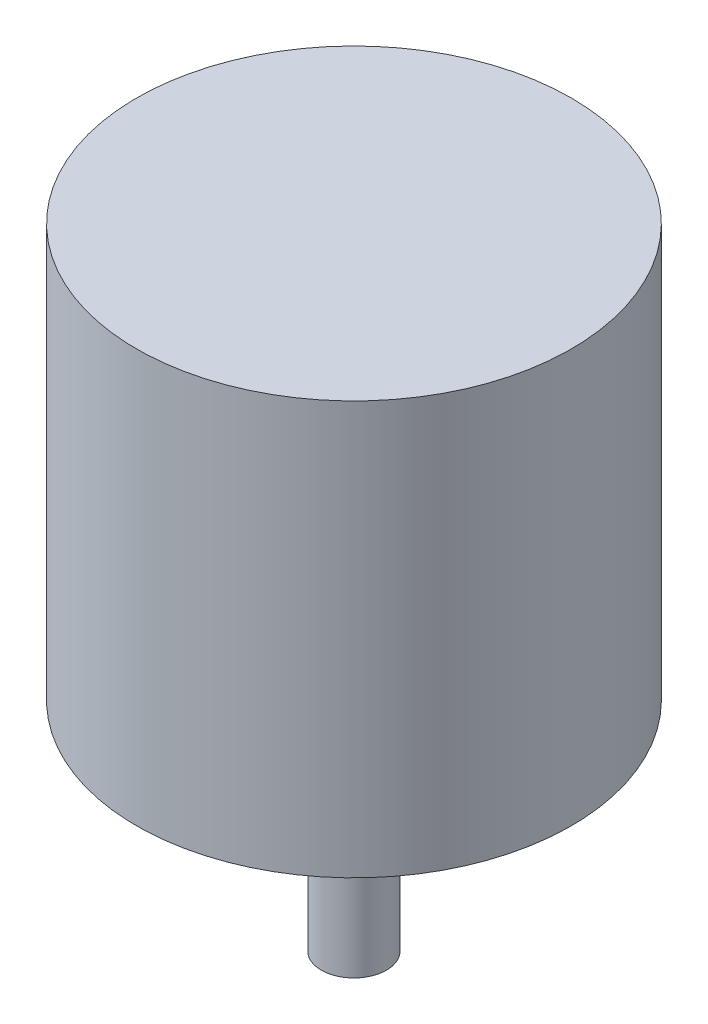
from build123d import *

# Parameters (mm, degrees)
ESBO_O11_R               = 20
RESSALTO_EXTRUS_O3_DEPTH = 38
ESBO_O12_R               = 10
RESSALTO_EXTRUS_O4_DEPTH = 5
ESBO_O13_R               = 3
RESSALTO_EXTRUS_O5_DEPTH = 15


with BuildPart() as part:
    # Esboço11 → Ressalto-extrusão3 (new body)
    with BuildSketch(Plane.XZ):
        Circle(ESBO_O11_R)
    extrude(amount=RESSALTO_EXTRUS_O3_DEPTH)

    # Esboço12 → Ressalto-extrusão4 (add)
    with BuildSketch(Plane.XZ.offset(38)):
        Circle(ESBO_O12_R)
    extrude(amount=RESSALTO_EXTRUS_O4_DEPTH)

    # Esboço13 → Ressalto-extrusão5 (add)
    with BuildSketch(Plane.XZ.offset(43)):
        Circle(ESBO_O13_R)
    extrude(amount=RESSALTO_EXTRUS_O5_DEPTH)


solid = part.part
